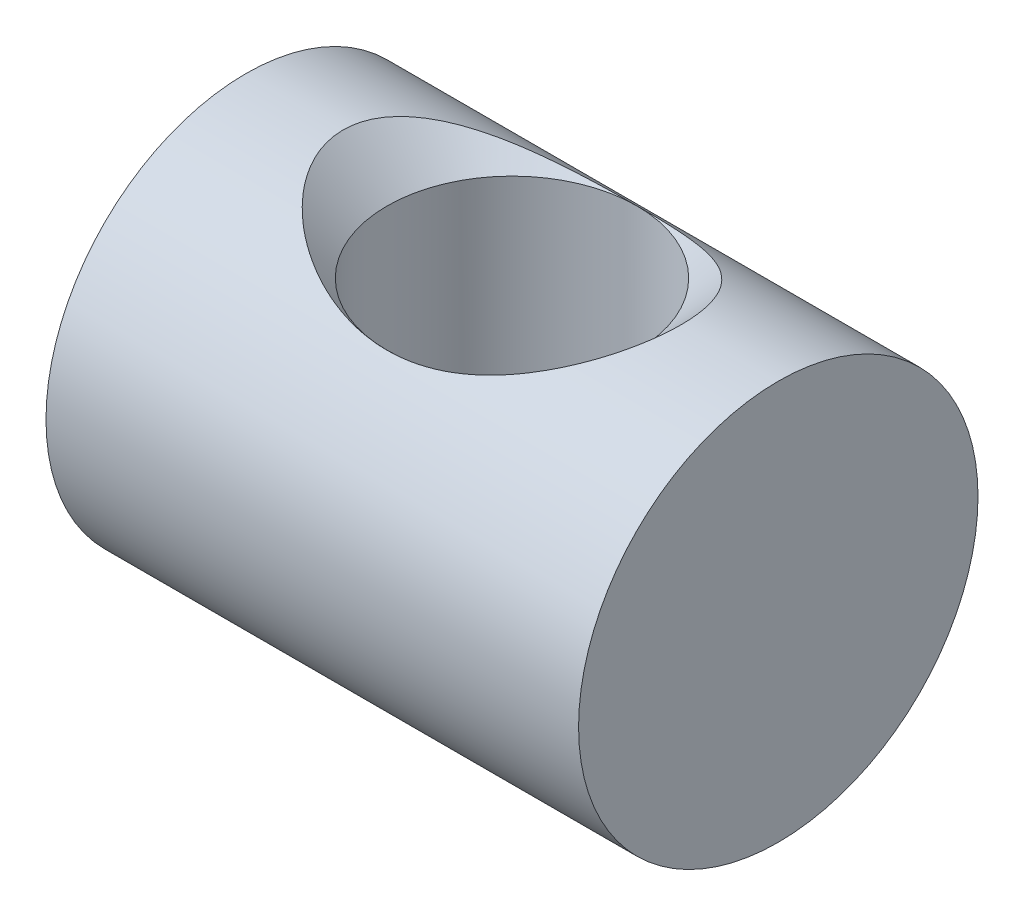
from build123d import *

# Parameters (mm, degrees)
SZKIC1_R                    = 15
DODANIE_WYCI_GNI_CIE1_DEPTH = 20
SKETCH1_R                   = 9.385297187
CUT_EXTRUDE1_DEPTH          = 34
CUT_EXTRUDE1_DEPTH_BACK     = 23


with BuildPart() as part:
    # Szkic1 → Dodanie-wyciągnięcie1 (new body, symmetric)
    with BuildSketch(Plane(origin=(0, 0, 0), x_dir=(0, 0, -1), z_dir=(1, 0, 0))):
        Circle(SZKIC1_R)
    extrude(amount=DODANIE_WYCI_GNI_CIE1_DEPTH, both=True)

    # Sketch1 → Cut-Extrude1 (cut, two sides)
    with BuildSketch(Plane(origin=(0, 0, 0), x_dir=(1, 0, 0), z_dir=(0, 1, 0))) as cut_extrude1_sk:
        with Locations(Location((0, 0, 0), (0, 0, 90))):  # turned: the seam where the file's is
            Circle(SKETCH1_R)
    extrude(amount=CUT_EXTRUDE1_DEPTH, mode=Mode.SUBTRACT)
    extrude(cut_extrude1_sk.sketch, amount=-CUT_EXTRUDE1_DEPTH_BACK, mode=Mode.SUBTRACT)

    # Sketch2 → Cut-Revolve1 (revolve, cut)
    with BuildSketch(Plane(origin=(0, 0, 0), x_dir=(0, 0, -1), z_dir=(1, 0, 0)), mode=Mode.PRIVATE) as cut_revolve1_sk:
        Polygon((0, 2.315822277), (0, 32.756739461), (-30.440917184, 32.756739461), align=None)
    revolve(cut_revolve1_sk.sketch.rotate(Axis((0, 2.315822277, 0), (0, 1, 0)), 180), axis=Axis((0, 2.315822277, 0), (0, 1, 0)), mode=Mode.SUBTRACT)  # turned: the seam where the file's is


solid = part.part
